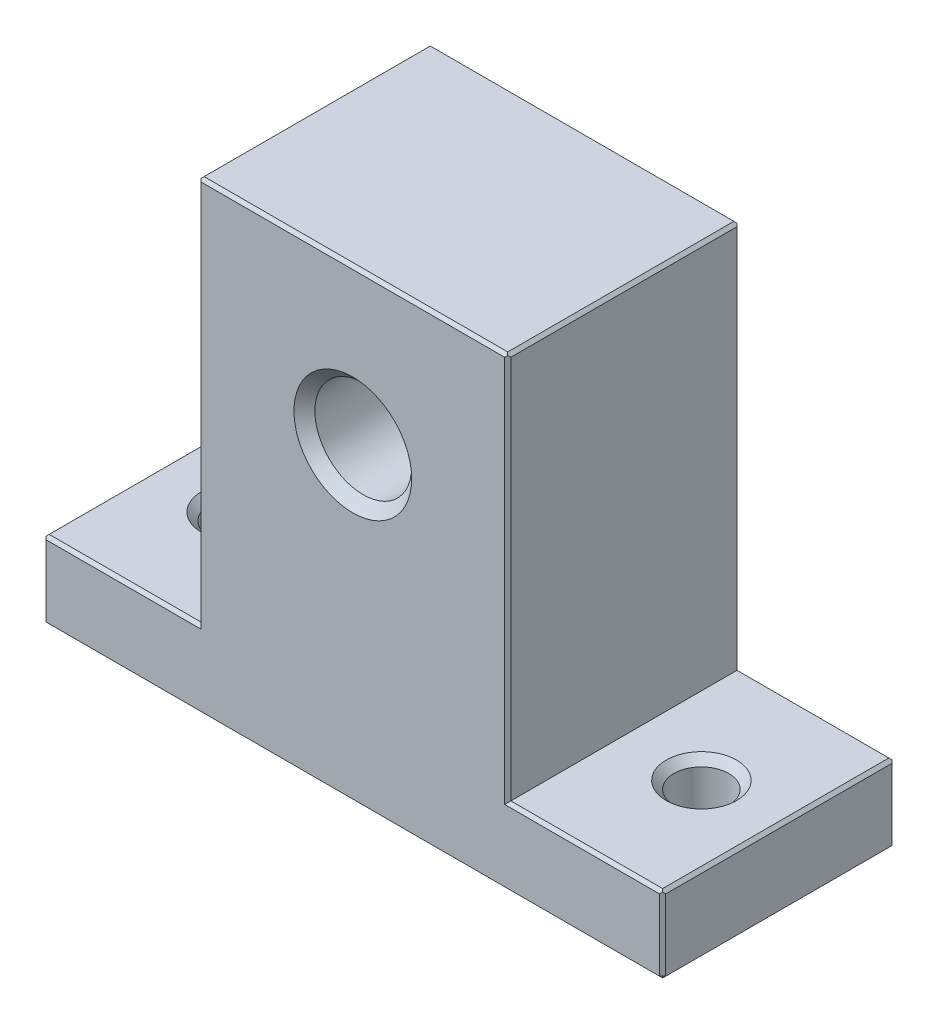
from build123d import *

# Parameters (mm, degrees)
BOSS_EXTRUDE1_DEPTH            = 6.35
BOSS_EXTRUDE2_DEPTH            = 38.1
F_8_CLEARANCE_HOLE1_AT_2_COUNT = 2
F_8_CLEARANCE_HOLE1_AT_2_PITCH = 38.1
CHAMFER1_SIZE                  = 0.254
CHAMFER2_SIZE                  = 0.254


with BuildPart() as part:
    # Sketch1 → Boss-Extrude1 (new body)
    with BuildSketch(Plane(origin=(0, 0, 0), x_dir=(1, 0, 0), z_dir=(0, 1, 0))):
        Polygon((-25.4, 9.525), (-25.4, -9.525), (-12.699999999999996, -9.525), (-12.700000000000003, 9.524999999999993), align=None)
        Polygon((-12.700000000000003, 9.524999999999993), (-12.699999999999996, -9.525), (12.700000000000003, -9.525), (12.700000000000003, 9.524999999999997), align=None)
        Polygon((12.700000000000003, 9.524999999999997), (12.700000000000003, -9.524999999999997), (25.4, -9.525), (25.4, 9.525), align=None)
    extrude(amount=BOSS_EXTRUDE1_DEPTH)

    # Sketch1_3 → Boss-Extrude2 (add)
    with BuildSketch(Plane(origin=(0, 0, 0), x_dir=(1, 0, 0), z_dir=(0, 1, 0))):
        Polygon((-12.700000000000003, 9.524999999999993), (-12.699999999999996, -9.525), (12.700000000000003, -9.525), (12.700000000000003, 9.524999999999997), align=None)
    extrude(amount=BOSS_EXTRUDE2_DEPTH)

    # Sketch4 → 3_8-16 Tapped Hole1 (revolve, cut)
    with BuildSketch(Plane(origin=(0, 25.4, 9.525), x_dir=(0, -1, 0), z_dir=(1, 0, 0))):
        Polygon((0, 0), (-4.67e-15, 19.05), (4.825999999999995, 19.05), (3.9687499999999956, 18.192749999999993), (3.9687499999999973, 0.8572500000000004), (4.826, 0), align=None)
    revolve(axis=Axis((0, 25.4, 15.874999999999991), (0, 0, -1)), mode=Mode.SUBTRACT)

    # Sketch8 → 8 Clearance Hole1 (revolve, cut)
    with BuildSketch(Plane(origin=(-19.05, 6.35, 4.66e-15), x_dir=(0, 0, 1), z_dir=(1, 0, 0))):
        Polygon((0, 0), (-1.56e-15, 6.350000000000001), (2.8828999999999985, 6.350000000000001), (2.247899999999996, 5.714999999999998), (2.247899999999997, 0.6350000000000001), (2.8829, 0), align=None)
    f_8_clearance_hole1 = revolve(axis=Axis((-19.05, 12.69999999999999, 4.66e-15), (0, -1, 0)), mode=Mode.SUBTRACT)

    # 8 Clearance Hole1 at 2: 8 Clearance Hole1 ×2
    with Locations(*[(i * F_8_CLEARANCE_HOLE1_AT_2_PITCH, 0, 0) for i in range(1, F_8_CLEARANCE_HOLE1_AT_2_COUNT)]):
        add(f_8_clearance_hole1, mode=Mode.SUBTRACT)

    # Chamfer1
    chamfer1_edges = [part.edges().sort_by_distance(p)[0] for p in [
        (25.4, 6.35, 0),
        (-19.05, 6.35, -9.525),
        (19.050000000000004, 6.35, 9.525),
        (19.050000000000004, 6.35, -9.525),
        (-25.4, 6.35, 0),
        (0, 38.1, -9.525),
        (-12.7, 38.1, 3.55e-15),
        (3.55e-15, 38.1, 9.525),
        (12.700000000000003, 38.1, 0),
        (-19.049999999999997, 6.35, 9.525),
    ]]
    chamfer(chamfer1_edges, length=CHAMFER1_SIZE)

    # Chamfer2
    chamfer2_edges = [part.edges().sort_by_distance(p)[0] for p in [
        (25.4, 3.048, -9.525),
        (25.4, 3.048, 9.525),
        (-25.4, 3.048, -9.525),
        (-25.4, 3.048, 9.525),
        (-25.4, 0, 0),
        (0, 0, -9.525),
        (25.4, 0, 0),
        (0, 0, 9.525),
        (12.700000000000003, 21.971000000000004, -9.524999999999999),
        (12.700000000000003, 21.971000000000004, 9.524999999999999),
        (-12.699999999999996, 21.971000000000004, 9.525),
        (-12.700000000000003, 21.971000000000004, -9.524999999999999),
    ]]
    chamfer(chamfer2_edges, length=CHAMFER2_SIZE)


solid = part.part
